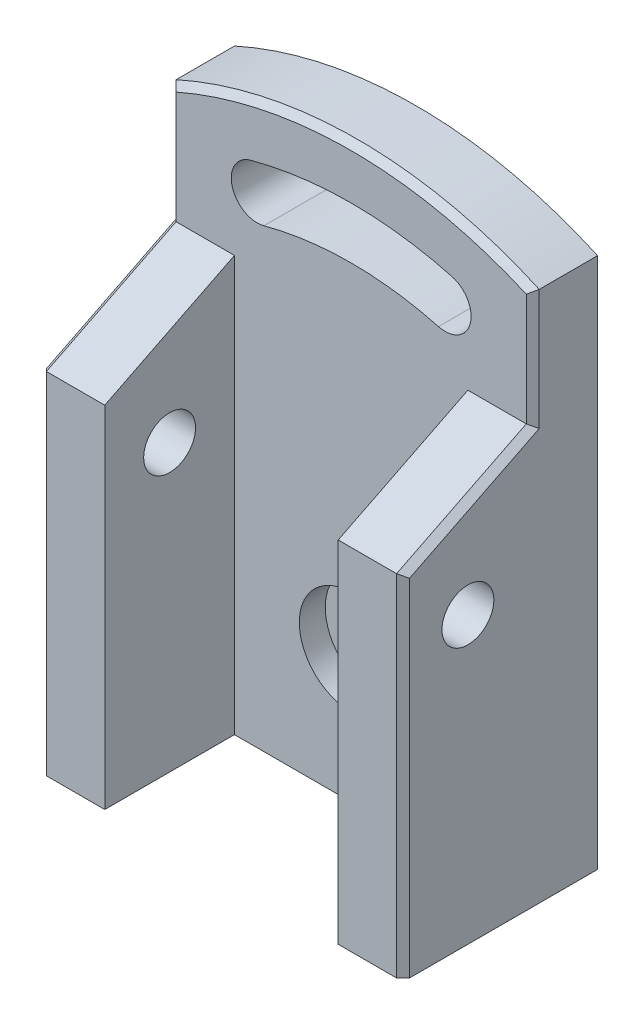
from build123d import *

# Parameters (mm, degrees)
BOSS_EXTRUDE2_DEPTH = 10
SKETCH1_4_R         = 8
CUT_EXTRUDE1_DEPTH  = 4
SKETCH1_6_R         = 4
CUT_EXTRUDE2_DEPTH  = 24
SKETCH2_R           = 4
BOSS_EXTRUDE3_DEPTH = 10
BOSS_EXTRUDE4_START = -10
SKETCH3_R           = 4
BOSS_EXTRUDE4_DEPTH = 10
CHAMFER1_SIZE       = 1


with BuildPart() as part:
    # Sketch1 → Boss-Extrude2 (new body)
    with BuildSketch(Plane.XY):
        with BuildLine():
            Line((-28, 81.967733539), (-28, 0))
            Line((-28, 0), (28, 0))
            Line((28, 0), (28, 81.967733539))
            ThreePointArc((28, 81.967733539), (0, 88), (-28, 81.967733539))
        make_face()
        with BuildLine():
            ThreePointArc((-15.529142706, 77.955549577), (0, 80), (15.529142706, 77.955549577))
            ThreePointArc((15.529142706, 77.955549577), (18.357569831, 73.056570092), (13.458590345, 70.228142967))
            ThreePointArc((13.458590345, 70.228142967), (0, 72), (-13.458590345, 70.228142967))
            ThreePointArc((-13.458590345, 70.228142967), (-18.357569831, 73.056570092), (-15.529142706, 77.955549577))
        make_face(mode=Mode.SUBTRACT)
    extrude(amount=-BOSS_EXTRUDE2_DEPTH)

    # Sketch1_4 → Cut-Extrude1 (cut)
    with BuildSketch(Plane.XY):
        with Locations((0, 20)):
            Circle(SKETCH1_4_R)
    extrude(amount=-CUT_EXTRUDE1_DEPTH, mode=Mode.SUBTRACT)

    # Sketch1_6 → Cut-Extrude2 (cut)
    with BuildSketch(Plane.XY):
        with Locations((0, 20)):
            Circle(SKETCH1_6_R)
    extrude(amount=-CUT_EXTRUDE2_DEPTH, mode=Mode.SUBTRACT)

    # Sketch2 → Boss-Extrude3 (add)
    with BuildSketch(Plane.ZY.offset(28)):
        Polygon((0, 64), (0, 0), (20, 0), (20, 54), align=None)
        with Locations((10, 44)):
            Circle(SKETCH2_R, mode=Mode.SUBTRACT)
    extrude(amount=-BOSS_EXTRUDE3_DEPTH)

    # Sketch3 → Boss-Extrude4 (add)
    with BuildSketch(Plane(origin=(28, 0, 0), x_dir=(0, 0, -1), z_dir=(1, 0, 0)).offset(BOSS_EXTRUDE4_START)):
        Polygon((-20, 54), (-20, 0), (0, 0), (0, 64), align=None)
        with Locations((-10, 44)):
            Circle(SKETCH3_R, mode=Mode.SUBTRACT)
    extrude(amount=BOSS_EXTRUDE4_DEPTH)

    # Chamfer1
    chamfer1_edges = [part.edges().sort_by_distance(p)[0] for p in [
        (28, 27, 20),
        (28, 59, 10),
        (28, 72.98386677, 0),
        (0, 88, 0),
        (-28, 72.98386677, 0),
        (-28, 59, 10),
        (-28, 27, 20),
    ]]
    chamfer(chamfer1_edges, length=CHAMFER1_SIZE)


solid = part.part
